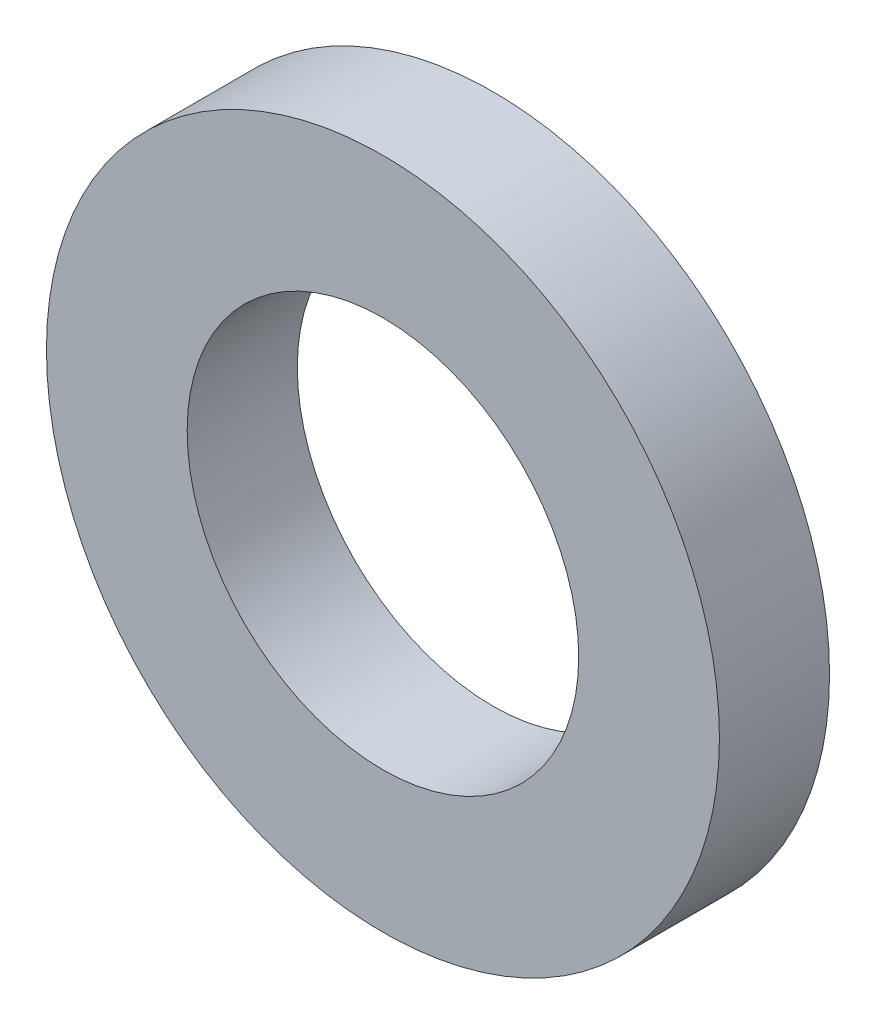
from build123d import *

# Parameters (mm, degrees)
SKETCH1_R           = 5.5
SKETCH1_R_2         = 3.2
BOSS_EXTRUDE1_DEPTH = 1.8


with BuildPart() as part:
    # Sketch1 → Boss-Extrude1 (new body)
    with BuildSketch(Plane.XY):
        Circle(SKETCH1_R)
        Circle(SKETCH1_R_2, mode=Mode.SUBTRACT)
    extrude(amount=BOSS_EXTRUDE1_DEPTH)


solid = part.part
